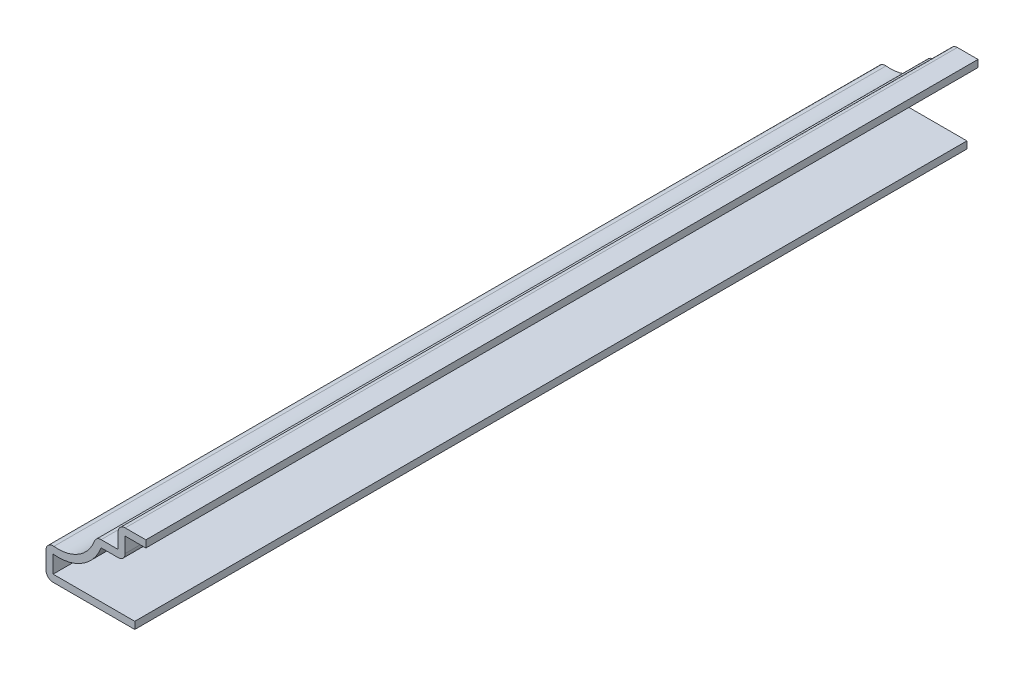
from build123d import *

# Parameters (mm, degrees)
EXTRUDE_THIN1_DEPTH = 119.0625
FILLET1_R           = 1.016


with BuildPart() as part:
    # Sketch1 → Extrude-Thin1 (new body)
    with BuildSketch(Plane.XY):
        with BuildLine():
            Line((0, 0), (-12.7, 0))
            Line((-12.7, 0), (-12.7, 4.7625))
            ThreePointArc((-12.7, 4.7625), (-8.258259272, 5.18111669), (-5.55625, 8.73125))
            Line((-5.55625, 8.73125), (-2.38125, 8.73125))
            Line((-2.38125, 8.73125), (-2.38125, 11.90625))
            Line((-2.38125, 11.90625), (1.5875, 11.90625))
            Line((1.5875, 11.90625), (1.5875, 10.89025))
            Line((1.5875, 10.89025), (-1.36525, 10.89025))
            Line((-1.36525, 10.89025), (-1.36525, 7.71525))
            Line((-1.36525, 7.71525), (-4.8085569, 7.71525))
            ThreePointArc((-4.8085569, 7.71525), (-7.525174126, 4.432825355), (-11.684, 3.506279057))
            Line((-11.684, 3.506279057), (-11.684, 1.016))
            Line((-11.684, 1.016), (0, 1.016))
            Line((0, 1.016), (0, 0))
        make_face()
    extrude(amount=-EXTRUDE_THIN1_DEPTH)

    # Fillet1
    fillet1_edges = [part.edges().sort_by_distance(p)[0] for p in [
        (-1.36525, 7.71525, -59.53125),
        (-12.7, 0, -59.53125),
        (-12.7, 4.7625, -59.53125),
        (-5.55625, 8.73125, -59.53125),
        (-2.38125, 11.90625, -59.53125),
    ]]
    fillet(fillet1_edges, radius=FILLET1_R)


solid = part.part
